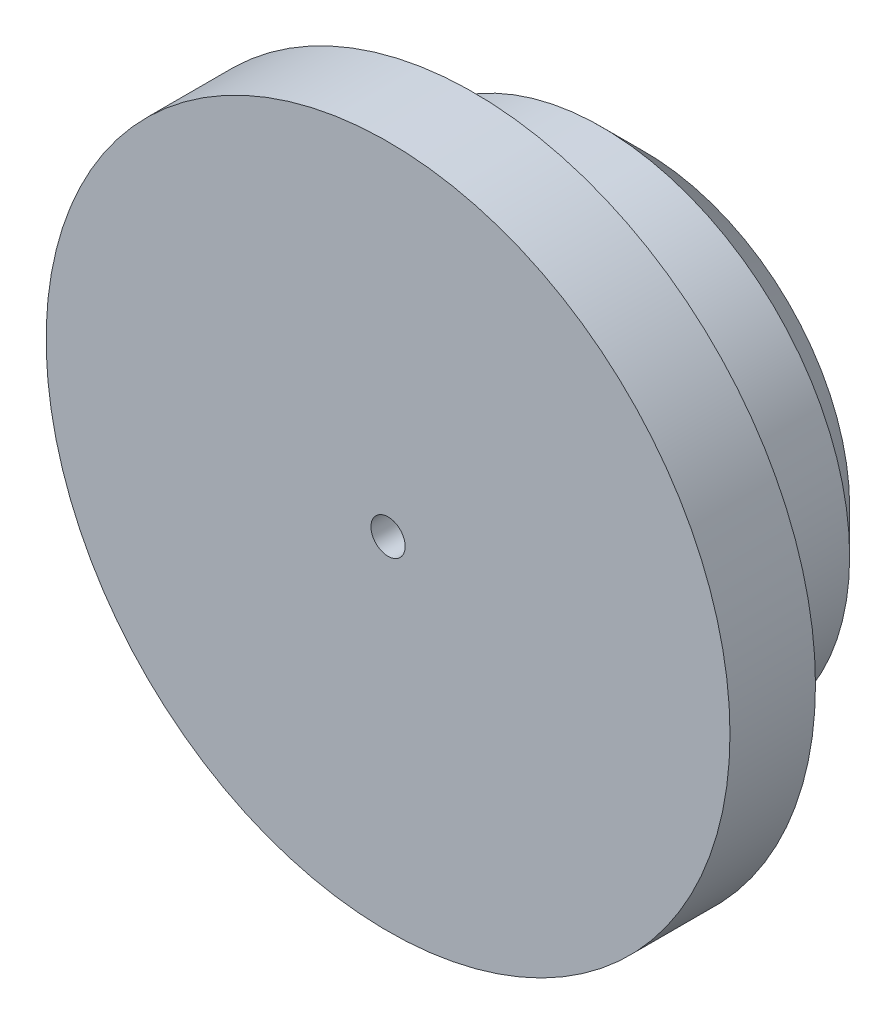
from build123d import *

# Parameters (mm, degrees)
ESQUISSE1_R             = 29
BOSS_EXTRU_1_DEPTH      = 20
ESQUISSE2_R             = 40
BOSS_EXTRU_2_DEPTH      = 10
CHANFREIN1_SIZE         = 5
ESQUISSE3_R             = 2
ENL_V_MAT_EXTRU_1_DEPTH = 30
ESQUISSE4_W             = 5
ESQUISSE4_H             = 7
BOSS_EXTRU_4_DEPTH      = 10


with BuildPart() as part:
    # Esquisse1 → Boss.-Extru.1 (new body)
    with BuildSketch(Plane.XY):
        Circle(ESQUISSE1_R)
    extrude(amount=BOSS_EXTRU_1_DEPTH)

    # Esquisse2 → Boss.-Extru.2 (add)
    with BuildSketch(Plane.XY.offset(20)):
        Circle(ESQUISSE2_R)
    extrude(amount=BOSS_EXTRU_2_DEPTH)

    # Chanfrein1
    chanfrein1_edges = [part.edges().sort_by_distance(p)[0] for p in [
        (-29, 0, 0),
    ]]
    chamfer(chanfrein1_edges, length=CHANFREIN1_SIZE)

    # Esquisse3 → Enlèv. mat.-Extru.1 (cut)
    with BuildSketch(Plane.XY.offset(30)):
        Circle(ESQUISSE3_R)
    extrude(amount=-ENL_V_MAT_EXTRU_1_DEPTH, mode=Mode.SUBTRACT)

    # Esquisse4 → Boss.-Extru.4 (add)
    with BuildSketch(Plane(origin=(0, 0, 0), x_dir=(-1, 0, 0), z_dir=(0, 0, -1))):
        with Locations((0, 6.5)):
            Rectangle(ESQUISSE4_W, ESQUISSE4_H)
        with Locations((0, -6.5)):
            Rectangle(ESQUISSE4_W, ESQUISSE4_H)
    extrude(amount=BOSS_EXTRU_4_DEPTH)


solid = part.part
